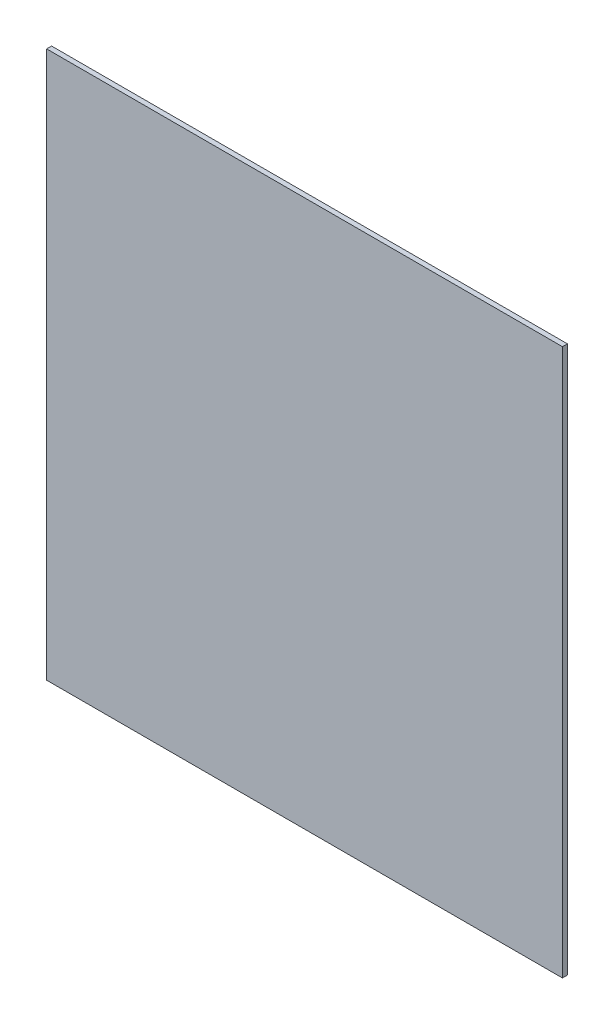
from build123d import *

# Parameters (mm, degrees)
SKETCH1_W           = 13.24
SKETCH1_H           = 14.03375
BOSS_EXTRUDE1_DEPTH = 0.127


with BuildPart() as part:
    # Sketch1 → Boss-Extrude1 (new body)
    with BuildSketch(Plane.XY):
        with Locations((-73.66, -84.3122297)):
            Rectangle(SKETCH1_W, SKETCH1_H)
    extrude(amount=BOSS_EXTRUDE1_DEPTH)


solid = part.part
